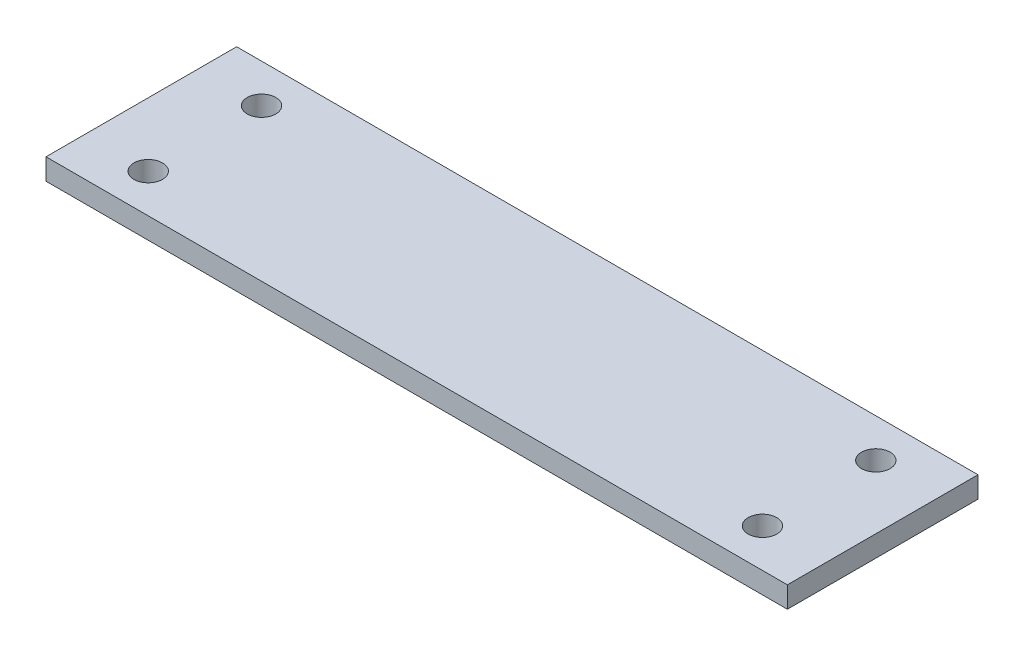
from build123d import *

# Parameters (mm, degrees)
SKETCH3_W           = 70
SKETCH3_H           = 18
SKETCH3_R           = 1.35
BOSS_EXTRUDE1_DEPTH = 2


with BuildPart() as part:
    # Sketch3 → Boss-Extrude1 (new body)
    with BuildSketch(Plane(origin=(0, 0, 0), x_dir=(1, 0, 0), z_dir=(0, 1, 0))):
        Rectangle(SKETCH3_W, SKETCH3_H)
        with Locations((-29, 5.35)):
            Circle(SKETCH3_R, mode=Mode.SUBTRACT)
        with Locations((29, 5.35)):
            Circle(SKETCH3_R, mode=Mode.SUBTRACT)
        with Locations((29, -5.35)):
            Circle(SKETCH3_R, mode=Mode.SUBTRACT)
        with Locations((-29, -5.35)):
            Circle(SKETCH3_R, mode=Mode.SUBTRACT)
    extrude(amount=BOSS_EXTRUDE1_DEPTH)


solid = part.part
